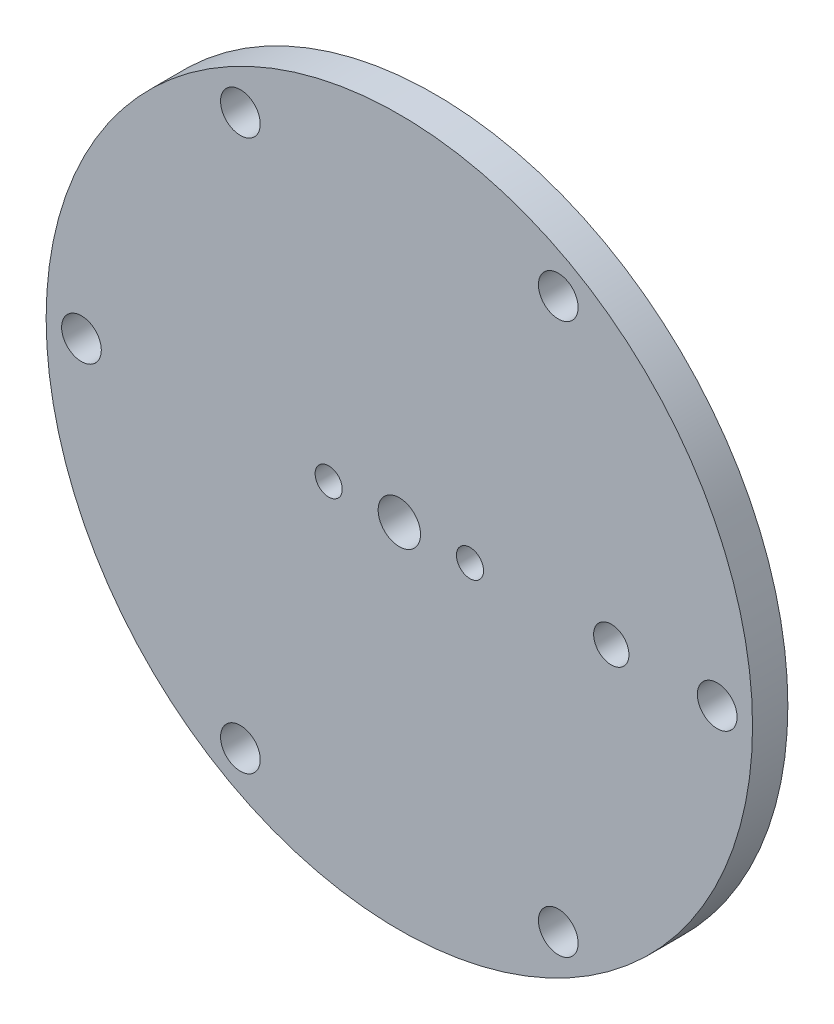
from build123d import *

# Parameters (mm, degrees)
SKETCH1_R                                         = 31.75
BOSS_EXTRUDE1_DEPTH                               = 3.175
CIRPATTERN1_COUNT                                 = 6
SKETCH5_R                                         = 1.905
CUT_EXTRUDE1_DEPTH                                = 4.175
CSK_FOR_2_FLAT_HEAD_MACHINE_SCREW_100_D           = 2.4384
CSK_FOR_2_FLAT_HEAD_MACHINE_SCREW_100_CSINK_D     = 4.3688
CSK_FOR_2_FLAT_HEAD_MACHINE_SCREW_100_CSINK_ANGLE = 100
SKETCH8_R                                         = 1.5875
CUT_EXTRUDE2_DEPTH                                = 4.175


with BuildPart() as part:
    # Sketch1 → Boss-Extrude1 (new body)
    with BuildSketch(Plane.XY):
        Circle(SKETCH1_R)
    extrude(amount=BOSS_EXTRUDE1_DEPTH)

    # Sketch4 → #28 (0.1405) Diameter Hole1 (revolve, cut)
    with BuildSketch(Plane(origin=(14.2875, 24.746675913, 3.175), x_dir=(0, -1, 0), z_dir=(1, 0, 0))):
        Polygon((0, 0), (0, 26.472145646), (1.78435, 25.4), (1.78435, 0), align=None)
    f_28_0_1405_diameter_hole1 = revolve(axis=Axis((14.2875, 24.746675913, 9.525), (0, 0, -1)), mode=Mode.SUBTRACT)

    # CirPattern1: #28 (0.1405) Diameter Hole1 ×6 about axis
    cirpattern1_axis = Axis((0, 0, 0), (0, 0, 1))
    for i in range(1, CIRPATTERN1_COUNT):
        add(f_28_0_1405_diameter_hole1.rotate(cirpattern1_axis, i * 360 / CIRPATTERN1_COUNT), mode=Mode.SUBTRACT)

    # Sketch5 → Cut-Extrude1 (cut, through all)
    with BuildSketch(Plane.XY.offset(3.175)):
        Circle(SKETCH5_R)
    extrude(amount=-CUT_EXTRUDE1_DEPTH, mode=Mode.SUBTRACT)

    # CSK for #2 Flat Head Machine Screw (100)1 (through all)
    with Locations(Plane(origin=(0, 0, 0), x_dir=(-1, 0, 0), z_dir=(0, 0, -1))):
        with Locations((6.35, 0), (-6.35, 0)):
            CounterSinkHole(CSK_FOR_2_FLAT_HEAD_MACHINE_SCREW_100_D / 2, CSK_FOR_2_FLAT_HEAD_MACHINE_SCREW_100_CSINK_D / 2, counter_sink_angle=CSK_FOR_2_FLAT_HEAD_MACHINE_SCREW_100_CSINK_ANGLE)

    # Sketch8 → Cut-Extrude2 (cut, through all)
    with BuildSketch(Plane.XY.offset(3.175)):
        with Locations((19.05, 0)):
            Circle(SKETCH8_R)
    extrude(amount=-CUT_EXTRUDE2_DEPTH, mode=Mode.SUBTRACT)


solid = part.part
